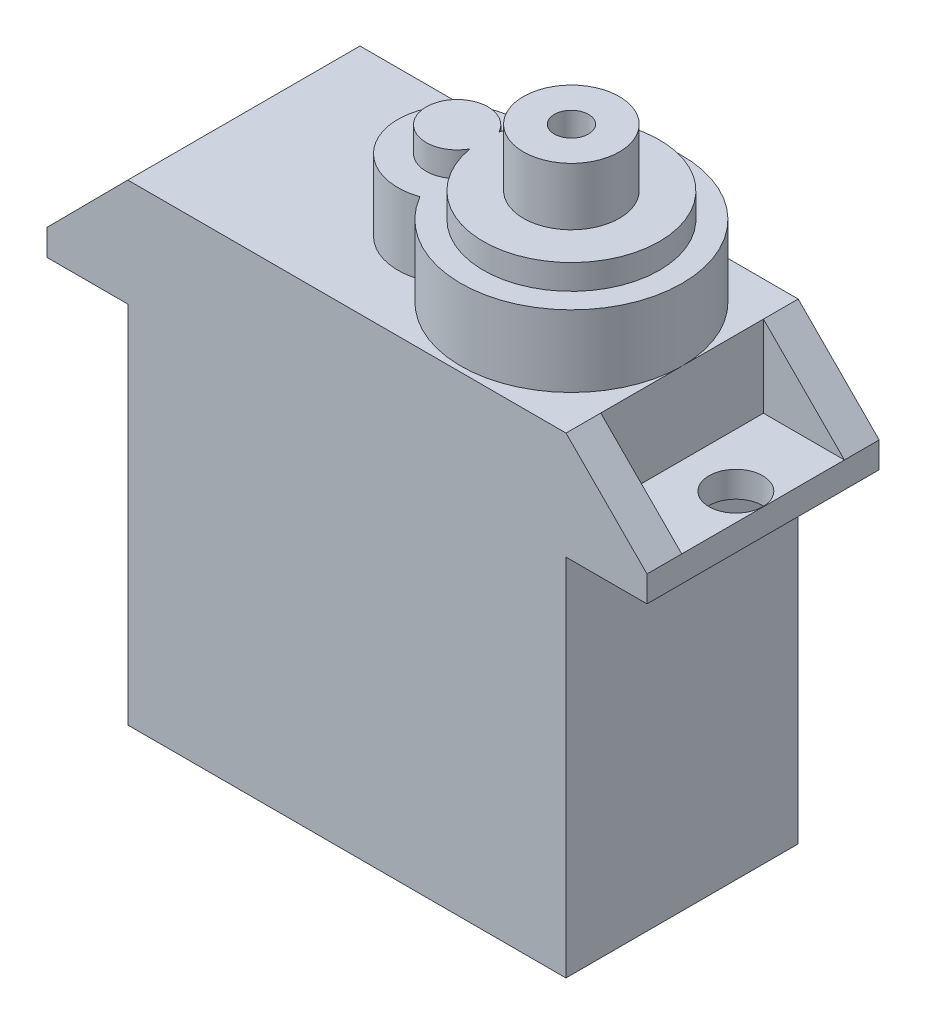
from build123d import *

# Parameters (mm, degrees)
SKETCH2_W           = 22.83
SKETCH2_H           = 12.1
BOSS_EXTRUDE1_DEPTH = 19
SKETCH3_W           = 31.28
SKETCH3_H           = 12.1
BOSS_EXTRUDE2_DEPTH = 5.6
CUT_EXTRUDE1_DEPTH  = 13.1
SKETCH6_W           = 4.22
SKETCH6_H           = 8.48
CUT_EXTRUDE2_DEPTH  = 4.25
CUT_EXTRUDE3_REACH  = 22.35
SKETCH7_R           = 1.4
SKETCH8_R           = 5.77
SKETCH8_R_2         = 3.085
BOSS_EXTRUDE3_DEPTH = 3.73
SKETCH9_R           = 4.59
SKETCH9_R_2         = 1.61
BOSS_EXTRUDE4_DEPTH = 1.3
SKETCH10_R          = 2.5
BOSS_EXTRUDE5_DEPTH = 3
SKETCH12_R          = 0.89
CUT_EXTRUDE4_DEPTH  = 14


with BuildPart() as part:
    # Sketch2 → Boss-Extrude1 (new body)
    with BuildSketch(Plane(origin=(0, 0, 0), x_dir=(1, 0, 0), z_dir=(0, 1, 0))):
        Rectangle(SKETCH2_W, SKETCH2_H)
    extrude(amount=BOSS_EXTRUDE1_DEPTH)

    # Sketch3 → Boss-Extrude2 (add)
    with BuildSketch(Plane(origin=(0, 19, 0), x_dir=(1, 0, 0), z_dir=(0, 1, 0))):
        Rectangle(SKETCH3_W, SKETCH3_H)
    extrude(amount=BOSS_EXTRUDE2_DEPTH)

    # Sketch5 → Cut-Extrude1 (cut, through all)
    with BuildSketch(Plane.XY.offset(6.05)):
        Polygon((-15.64, 20.35), (-11.42, 24.6), (-15.64, 24.6), align=None)
        Polygon((15.64, 24.6), (15.64, 20.35), (11.42, 24.6), align=None)
    extrude(amount=-CUT_EXTRUDE1_DEPTH, mode=Mode.SUBTRACT)

    # Sketch6 → Cut-Extrude2 (cut)
    with BuildSketch(Plane(origin=(0, 24.6, 0), x_dir=(1, 0, 0), z_dir=(0, 1, 0))):
        with Locations((13.53, 0)):
            Rectangle(SKETCH6_W, SKETCH6_H)
        with Locations((-13.53, 0)):
            Rectangle(SKETCH6_W, SKETCH6_H)
    extrude(amount=-CUT_EXTRUDE2_DEPTH, mode=Mode.SUBTRACT)

    # Sketch7 → Cut-Extrude3 (cut, up to next)
    with BuildSketch(Plane(origin=(0, 20.35, 0), x_dir=(1, 0, 0), z_dir=(0, 1, 0)), mode=Mode.PRIVATE) as cut_extrude3_sk1:
        with Locations((14.22, 0)):
            Circle(SKETCH7_R)
    cut_extrude3_tool1 = extrude(cut_extrude3_sk1.sketch, amount=-CUT_EXTRUDE3_REACH, mode=Mode.PRIVATE) & part.part
    add(cut_extrude3_tool1.solids().sort_by_distance((14.22, 20.35, 0))[0], mode=Mode.SUBTRACT)
    # Sketch7 → Cut-Extrude3 (cut, up to next)
    with BuildSketch(Plane(origin=(0, 20.35, 0), x_dir=(1, 0, 0), z_dir=(0, 1, 0)), mode=Mode.PRIVATE) as cut_extrude3_sk2:
        with Locations((-14.22, 0)):
            Circle(SKETCH7_R)
    cut_extrude3_tool2 = extrude(cut_extrude3_sk2.sketch, amount=-CUT_EXTRUDE3_REACH, mode=Mode.PRIVATE) & part.part
    add(cut_extrude3_tool2.solids().sort_by_distance((-14.22, 20.35, 0))[0], mode=Mode.SUBTRACT)

    # Sketch8 → Boss-Extrude3 (add)
    with BuildSketch(Plane(origin=(0, 24.6, 0), x_dir=(1, 0, 0), z_dir=(0, 1, 0))):
        with Locations((5.65, 0)):
            Circle(SKETCH8_R)
        with Locations((-0.305, 0)):
            Circle(SKETCH8_R_2)
    extrude(amount=BOSS_EXTRUDE3_DEPTH)

    # Sketch9 → Boss-Extrude4 (add)
    with BuildSketch(Plane(origin=(0, 28.33, 0), x_dir=(1, 0, 0), z_dir=(0, 1, 0))):
        with Locations((5.65, 0)):
            Circle(SKETCH9_R)
        with Locations((-0.305, 0)):
            Circle(SKETCH9_R_2)
    extrude(amount=BOSS_EXTRUDE4_DEPTH)

    # Sketch10 → Boss-Extrude5 (add)
    with BuildSketch(Plane(origin=(0, 29.63, 0), x_dir=(1, 0, 0), z_dir=(0, 1, 0))):
        with Locations((5.65, 0)):
            Circle(SKETCH10_R)
    extrude(amount=BOSS_EXTRUDE5_DEPTH)

    # Sketch12 → Cut-Extrude4 (cut)
    with BuildSketch(Plane(origin=(0, 32.63, 0), x_dir=(1, 0, 0), z_dir=(0, 1, 0))):
        with Locations((5.65, 0)):
            Circle(SKETCH12_R)
    extrude(amount=-CUT_EXTRUDE4_DEPTH, mode=Mode.SUBTRACT)


solid = part.part
